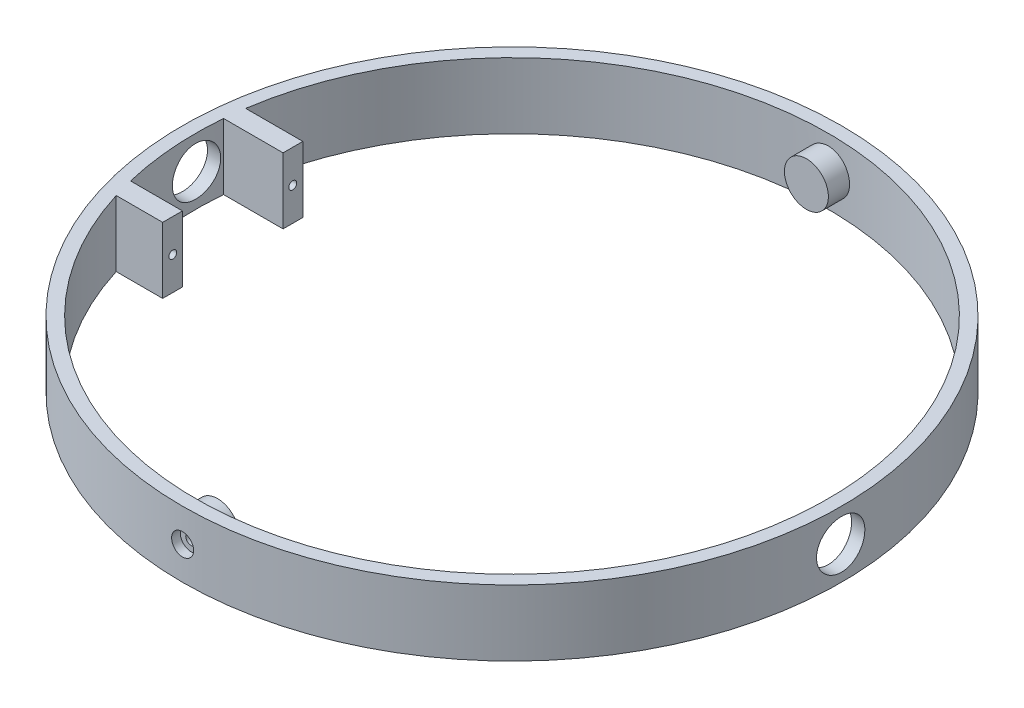
from build123d import *

# Parameters (mm, degrees)
SKETCH1_R               = 75
SKETCH1_R_2             = 72
BOSS_EXTRUDE1_DEPTH     = 15
SKETCH2_R               = 5.5
CUT_EXTRUDE1_DEPTH      = 76
CUT_EXTRUDE1_DEPTH_BACK = 76
BOSS_EXTRUDE2_START     = -6
SKETCH3_R               = 5
BOSS_EXTRUDE2_DEPTH     = 7
SKETCH4_W               = 11.8125703
SKETCH4_H               = 4.5
SKETCH4_W_2             = 13.541131856
BOSS_EXTRUDE3_DEPTH     = 15
SKETCH5_R               = 0.9
CUT_EXTRUDE2_DEPTH      = 8
SKETCH6_R               = 2.45
CUT_EXTRUDE3_DEPTH      = 4
SKETCH7_R               = 1.25
CUT_EXTRUDE4_DEPTH      = 4
SKETCH8_R               = 2.5
CUT_EXTRUDE5_DEPTH      = 4


with BuildPart() as part:
    # Sketch1 → Boss-Extrude1 (new body)
    with BuildSketch(Plane(origin=(0, 0, 0), x_dir=(1, 0, 0), z_dir=(0, 1, 0))):
        Circle(SKETCH1_R)
        Circle(SKETCH1_R_2, mode=Mode.SUBTRACT)
    extrude(amount=BOSS_EXTRUDE1_DEPTH)

    # Sketch2 → Cut-Extrude1 (cut, two sides)
    with BuildSketch(Plane(origin=(0, 0, 0), x_dir=(0, 0, -1), z_dir=(1, 0, 0))) as cut_extrude1_sk:
        with Locations((0, 7.5)):
            Circle(SKETCH2_R)
    extrude(amount=CUT_EXTRUDE1_DEPTH, mode=Mode.SUBTRACT)
    extrude(cut_extrude1_sk.sketch, amount=-CUT_EXTRUDE1_DEPTH_BACK, mode=Mode.SUBTRACT)

    # Sketch3 → Boss-Extrude2 (add)
    with BuildSketch(Plane.XY.offset(73).offset(BOSS_EXTRUDE2_START)):
        with Locations((0, 7.5)):
            Circle(SKETCH3_R)
    boss_extrude2 = extrude(amount=BOSS_EXTRUDE2_DEPTH)

    # Mirror1: Boss-Extrude2 across plane
    add(boss_extrude2.mirror(Plane.XY))

    # Sketch4 → Boss-Extrude3 (add)
    with BuildSketch(Plane(origin=(0, 15, 0), x_dir=(1, 0, 0), z_dir=(0, 1, 0))):
        with Locations((-64.10628515, -19.05)):
            Rectangle(SKETCH4_W, SKETCH4_H)
        with Locations((-64.970565928, 8.35)):
            Rectangle(SKETCH4_W_2, SKETCH4_H)
    extrude(amount=-BOSS_EXTRUDE3_DEPTH)

    # Sketch5 → Cut-Extrude2 (cut)
    with BuildSketch(Plane(origin=(-58.2, 0, 0), x_dir=(0, 0, -1), z_dir=(1, 0, 0))):
        with Locations((8.3, 7.5)):
            Circle(SKETCH5_R)
        with Locations((-19, 7.5)):
            Circle(SKETCH5_R)
    extrude(amount=-CUT_EXTRUDE2_DEPTH, mode=Mode.SUBTRACT)

    # Sketch6 → Cut-Extrude3 (cut)
    with BuildSketch(Plane(origin=(0, 0, 67), x_dir=(-1, 0, 0), z_dir=(0, 0, -1))):
        with Locations((0, 7.5)):
            Circle(SKETCH6_R)
    extrude(amount=-CUT_EXTRUDE3_DEPTH, mode=Mode.SUBTRACT)

    # Sketch7 → Cut-Extrude4 (cut)
    with BuildSketch(Plane(origin=(0, 0, 71), x_dir=(-1, 0, 0), z_dir=(0, 0, -1))):
        with Locations((0, 7.5)):
            Circle(SKETCH7_R)
    extrude(amount=-CUT_EXTRUDE4_DEPTH, mode=Mode.SUBTRACT)

    # Sketch8 → Cut-Extrude5 (cut)
    with BuildSketch(Plane(origin=(0, 0, 73), x_dir=(-1, 0, 0), z_dir=(0, 0, -1))):
        with Locations((0, 7.5)):
            Circle(SKETCH8_R)
    extrude(amount=-CUT_EXTRUDE5_DEPTH, mode=Mode.SUBTRACT)


solid = part.part
